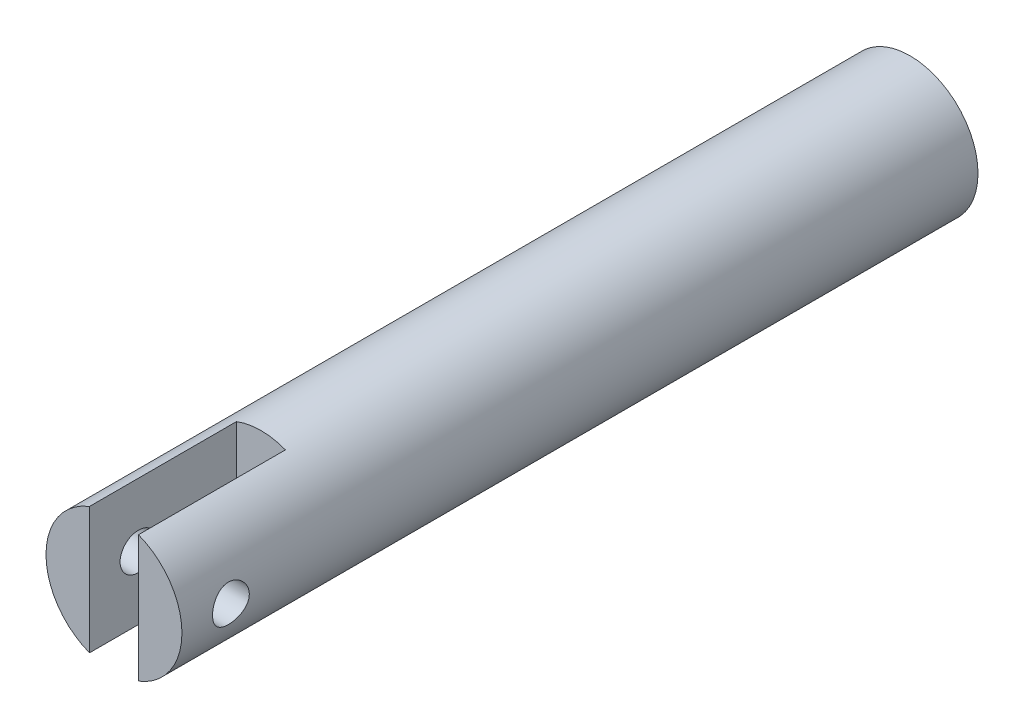
from build123d import *

# Parameters (mm, degrees)
ESQUISSE1_R                  = 5.55
BOSS_EXTRU_1_DEPTH           = 65
ENL_V_MAT_EXTRU_1_DEPTH      = 12
ESQUISSE3_R                  = 1.5
ENL_V_MAT_EXTRU_2_DEPTH      = 6.55
ENL_V_MAT_EXTRU_2_DEPTH_BACK = 6.55


with BuildPart() as part:
    # Esquisse1 → Boss.-Extru.1 (new body)
    with BuildSketch(Plane.XY):
        Circle(ESQUISSE1_R)
    extrude(amount=BOSS_EXTRU_1_DEPTH)

    # Esquisse2 → Enlèv. mat.-Extru.1 (cut)
    with BuildSketch(Plane.XY.offset(65)):
        with BuildLine():
            Line((-2, 5.177113095), (-2, -5.177113095))
            ThreePointArc((-2, -5.177113095), (0, -5.55), (2, -5.177113095))
            Line((2, -5.177113095), (2, 5.177113095))
            ThreePointArc((2, 5.177113095), (0, 5.55), (-2, 5.177113095))
        make_face()
    extrude(amount=-ENL_V_MAT_EXTRU_1_DEPTH, mode=Mode.SUBTRACT)

    # Esquisse3 → Enlèv. mat.-Extru.2 (cut, two sides)
    with BuildSketch(Plane(origin=(0, 0, 0), x_dir=(0, 0, -1), z_dir=(1, 0, 0))) as enl_v_mat_extru_2_sk:
        with Locations((-61, 0)):
            Circle(ESQUISSE3_R)
    extrude(amount=ENL_V_MAT_EXTRU_2_DEPTH, mode=Mode.SUBTRACT)
    extrude(enl_v_mat_extru_2_sk.sketch, amount=-ENL_V_MAT_EXTRU_2_DEPTH_BACK, mode=Mode.SUBTRACT)


solid = part.part
